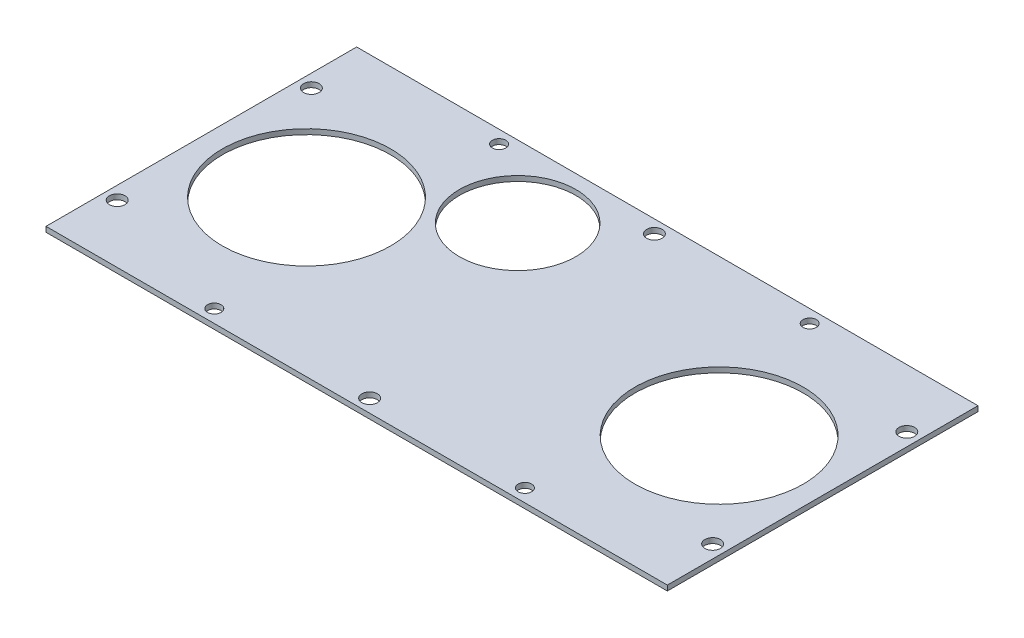
from build123d import *

# Parameters (mm, degrees)
SKETCH1_W           = 304.8
SKETCH1_H           = 152.4
SKETCH1_R           = 41.275
SKETCH1_R_2         = 3.81
SKETCH1_R_3         = 3.302
BOSS_EXTRUDE1_DEPTH = 2.54
SKETCH2_R           = 28.575
CUT_EXTRUDE1_DEPTH  = 3.54


with BuildPart() as part:
    # Sketch1 → Boss-Extrude1 (new body)
    with BuildSketch(Plane(origin=(0, 0, 0), x_dir=(1, 0, 0), z_dir=(0, 1, 0))):
        Rectangle(SKETCH1_W, SKETCH1_H)
        with Locations((-100.803124952, 0)):
            Circle(SKETCH1_R, mode=Mode.SUBTRACT)
        with Locations((101.6, 0)):
            Circle(SKETCH1_R, mode=Mode.SUBTRACT)
        with Locations((146.05, 47.625)):
            Circle(SKETCH1_R_2, mode=Mode.SUBTRACT)
        with Locations((76.2, 69.85)):
            Circle(SKETCH1_R_3, mode=Mode.SUBTRACT)
        with Locations((-146.05, 47.625)):
            Circle(SKETCH1_R_2, mode=Mode.SUBTRACT)
        with Locations((-146.05, -47.625)):
            Circle(SKETCH1_R_2, mode=Mode.SUBTRACT)
        with Locations((-76.2, -69.85)):
            Circle(SKETCH1_R_3, mode=Mode.SUBTRACT)
        with Locations((76.2, -69.85)):
            Circle(SKETCH1_R_3, mode=Mode.SUBTRACT)
        with Locations((146.05, -47.625)):
            Circle(SKETCH1_R_2, mode=Mode.SUBTRACT)
        with Locations((0, -69.85)):
            Circle(SKETCH1_R_2, mode=Mode.SUBTRACT)
        with Locations((-76.2, 69.85)):
            Circle(SKETCH1_R_3, mode=Mode.SUBTRACT)
        with Locations((0, 69.85)):
            Circle(SKETCH1_R_2, mode=Mode.SUBTRACT)
    extrude(amount=BOSS_EXTRUDE1_DEPTH)

    # Sketch2 → Cut-Extrude1 (cut, through all)
    with BuildSketch(Plane(origin=(0, 2.54, 0), x_dir=(1, 0, 0), z_dir=(0, 1, 0))):
        with Locations((-38.1, 40.8686)):
            Circle(SKETCH2_R)
    extrude(amount=-CUT_EXTRUDE1_DEPTH, mode=Mode.SUBTRACT)


solid = part.part
